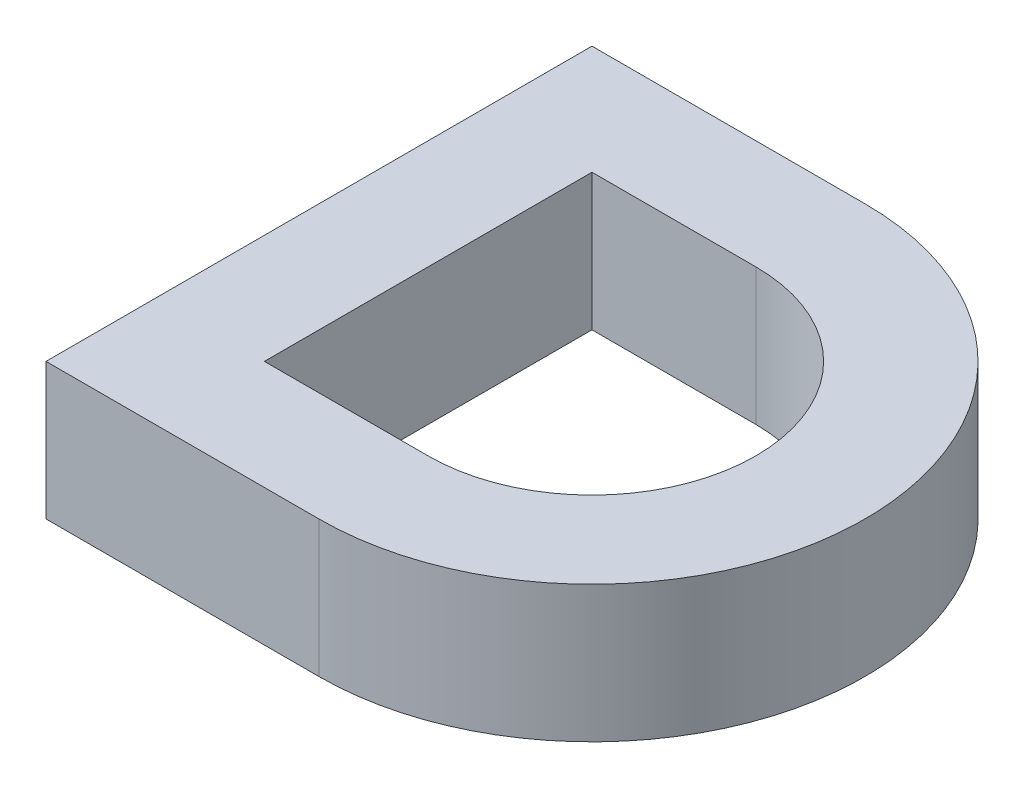
from build123d import *

# Parameters (mm, degrees)
BOSS_EXTRUDE1_DEPTH = 10


with BuildPart() as part:
    # Sketch1 → Boss-Extrude1 (new body)
    with BuildSketch(Plane(origin=(0, 0, 0), x_dir=(1, 0, 0), z_dir=(0, 1, 0))):
        with BuildLine():
            Line((150, 0), (150, 40))
            Line((150, 40), (170, 40))
            ThreePointArc((170, 40), (190, 20), (170, 0))
            Line((170, 0), (150, 0))
        make_face()
        with BuildLine():
            Line((170, 32), (158, 32))
            Line((158, 32), (158, 8))
            Line((158, 8), (170, 8))
            ThreePointArc((170, 8), (182, 20), (170, 32))
        make_face(mode=Mode.SUBTRACT)
    extrude(amount=BOSS_EXTRUDE1_DEPTH)


solid = part.part
